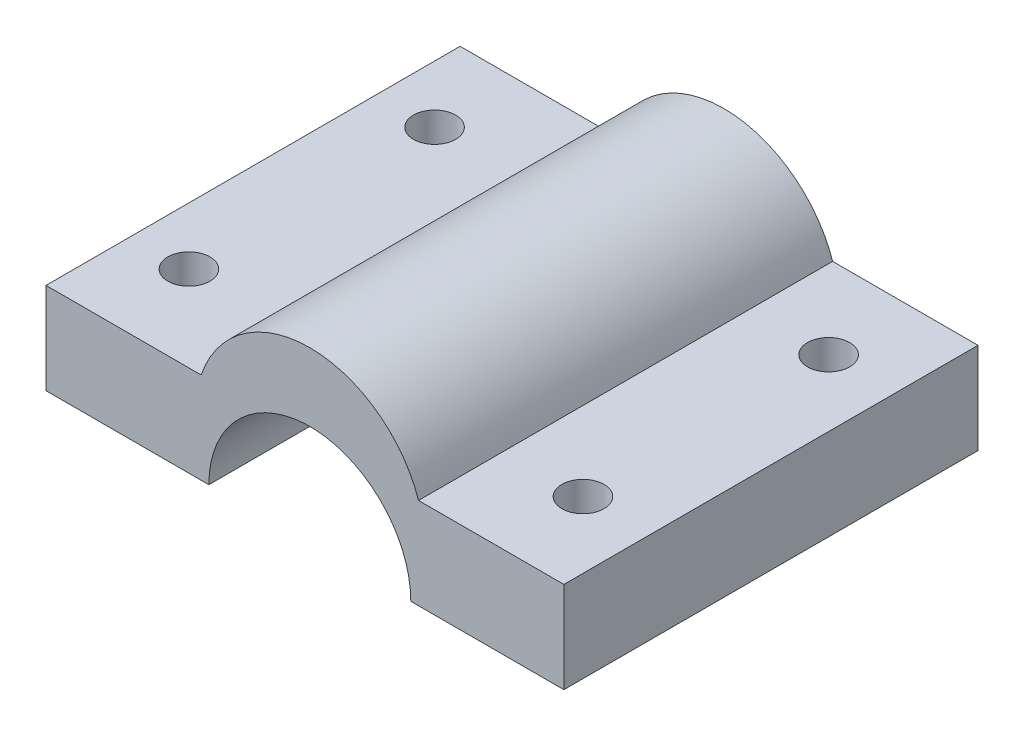
from build123d import *

# Parameters (mm, degrees)
BOSS_EXTRUDE1_DEPTH = 50
SKETCH2_R           = 2.545489134
CUT_EXTRUDE1_DEPTH  = 50


with BuildPart() as part:
    # Sketch1 → Boss-Extrude1 (new body)
    with BuildSketch(Plane.XY):
        with BuildLine():
            Line((-9.516237222, -14.74726776), (8.035250311, -14.74726776))
            Line((8.035250311, -14.74726776), (8.035250311, -25.75856102))
            Line((8.035250311, -25.75856102), (-10.447991948, -25.75856102))
            ThreePointArc((-10.447991948, -25.75856102), (-22.639066629, -13.567486339), (-34.83014131, -25.75856102))
            Line((-34.83014131, -25.75856102), (-54.49316499, -25.75856102))
            Line((-54.49316499, -25.75856102), (-54.49316499, -14.74726776))
            Line((-54.49316499, -14.74726776), (-35.761896036, -14.74726776))
            ThreePointArc((-35.761896036, -14.74726776), (-22.639066629, -5.330023584), (-9.516237222, -14.74726776))
        make_face()
    extrude(amount=BOSS_EXTRUDE1_DEPTH)

    # Sketch2 → Cut-Extrude1 (cut)
    with BuildSketch(Plane(origin=(0, 0, 0), x_dir=(1, 0, 0), z_dir=(0, 1, 0))):
        with Locations((-47.57711427, -10.003748799)):
            Circle(SKETCH2_R)
        with Locations((0, -10.003748799)):
            Circle(SKETCH2_R)
        with Locations((0, -39.664230879)):
            Circle(SKETCH2_R)
        with Locations((-47.57711427, -39.664230879)):
            Circle(SKETCH2_R)
    extrude(amount=-CUT_EXTRUDE1_DEPTH, mode=Mode.SUBTRACT)


solid = part.part
